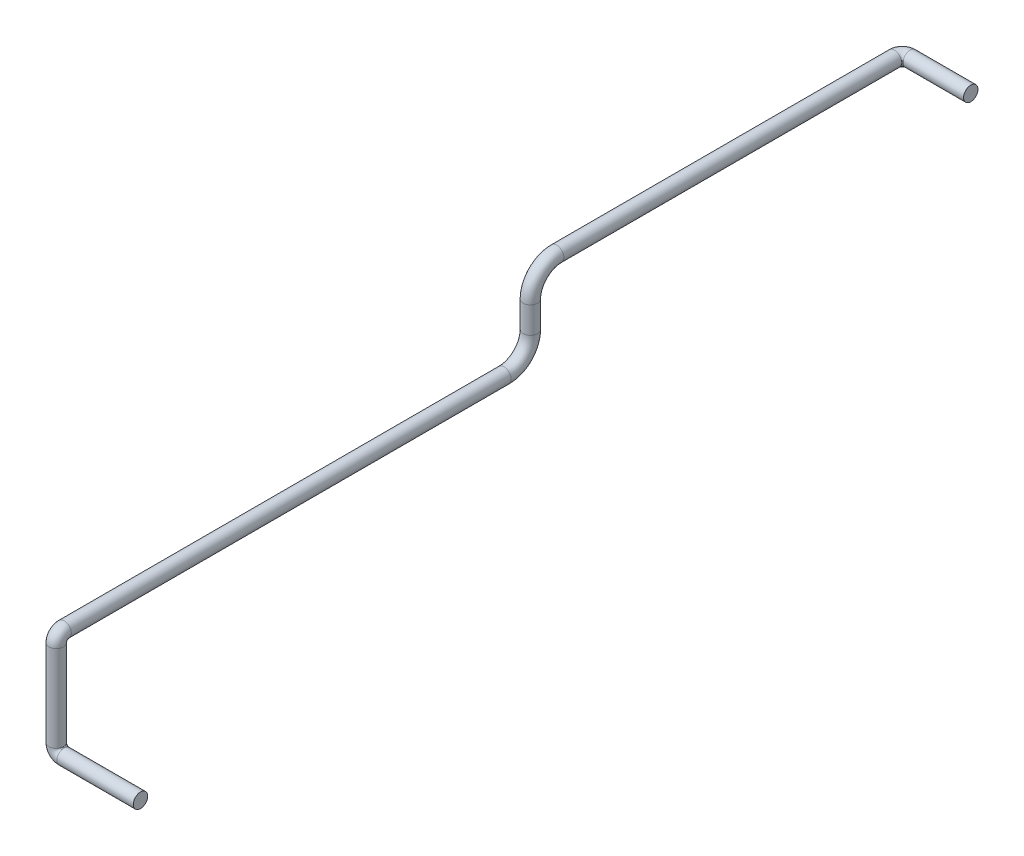
from build123d import *

# Parameters (mm, degrees)
CROQUIS1_R = 13.7


with BuildPart() as part:
    # Barrer1: sweep along a curve in space
    with BuildLine() as barrer1_path:
        Line((0, 0, 0), (-145, 0, 0))
        ThreePointArc((-145, 0, 0), (-155.606601718, 4.393398282, 0), (-160, 15, 0))
        Line((-160, 15, 0), (-160, 179, 0))
        ThreePointArc((-160, 194, -15), (-160, 189.606601718, -4.393398282), (-160, 179, 0))
        Line((-160, 194, -15), (-160, 194, -850))
        ThreePointArc((-160, 244, -900), (-160, 208.644660941, -885.355339059), (-160, 194, -850))
        Line((-160, 294, -900), (-160, 244, -900))
        ThreePointArc((-160, 294, -900), (-160, 329.355339059, -914.644660941), (-160, 344, -950))
        Line((-160, 344, -950), (-160, 344, -1591))
        ThreePointArc((-160, 344, -1591), (-155.606601718, 344, -1601.606601718), (-145, 344, -1606))
        Line((-145, 344, -1606), (-30, 344, -1606))
    # Croquis1 → Barrer1 (sweep)
    with BuildSketch(Plane(origin=(0, 0, 0), x_dir=(0, 0, -1), z_dir=(1, 0, 0))):
        Circle(CROQUIS1_R)
    sweep(path=barrer1_path.line)


solid = part.part
